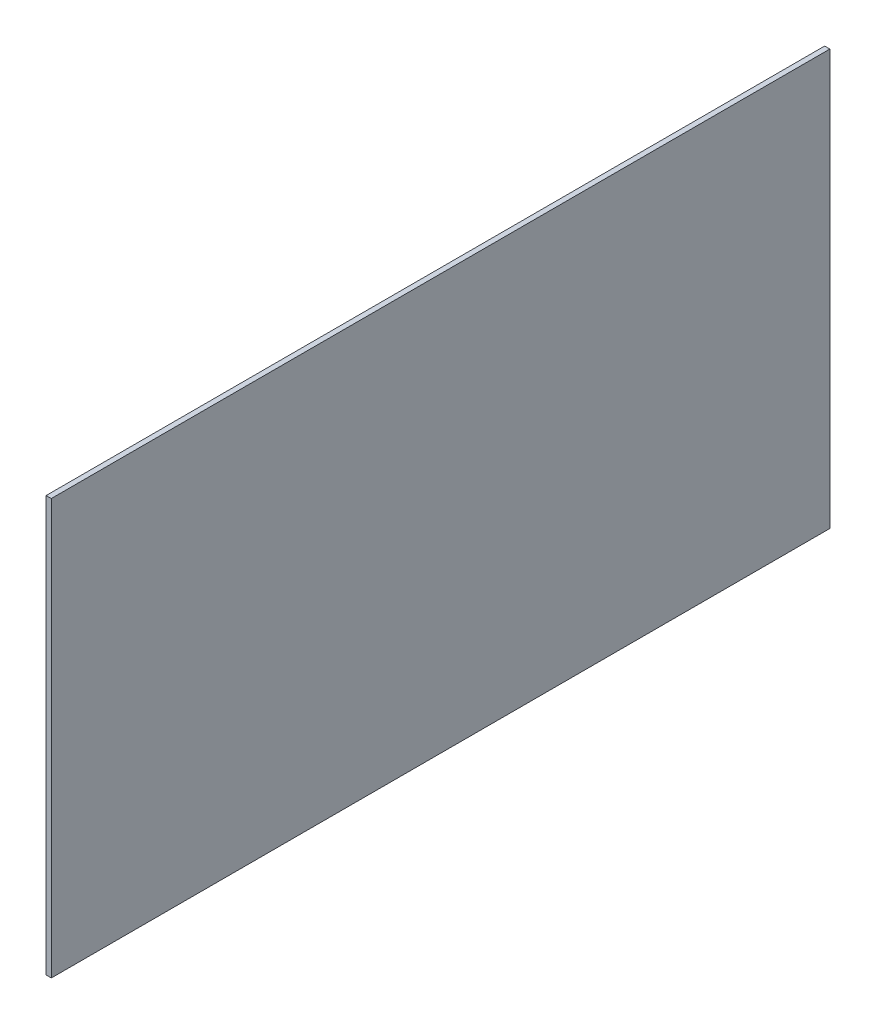
from build123d import *

# Parameters (mm, degrees)
SKETCH1_W           = 450
SKETCH1_H           = 240
BOSS_EXTRUDE1_DEPTH = 1.5


with BuildPart() as part:
    # Sketch1 → Boss-Extrude1 (new body, symmetric)
    with BuildSketch(Plane(origin=(0, 0, 0), x_dir=(0, 0, -1), z_dir=(1, 0, 0))):
        Rectangle(SKETCH1_W, SKETCH1_H)
    extrude(amount=BOSS_EXTRUDE1_DEPTH, both=True)


solid = part.part
